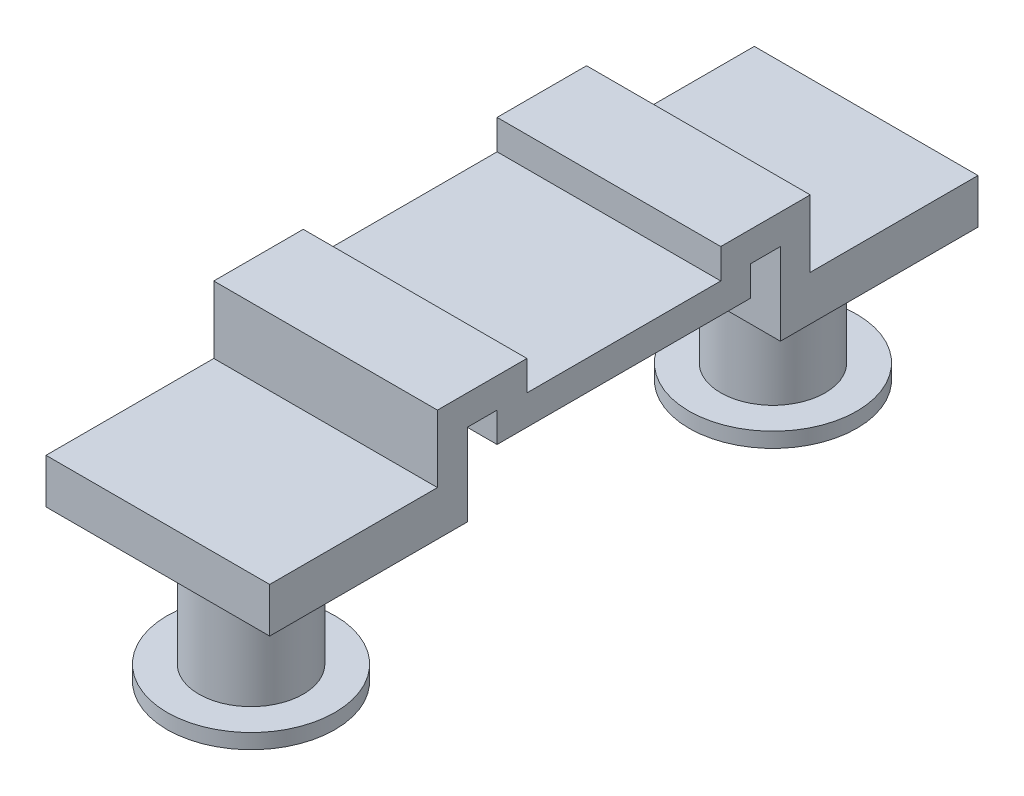
from build123d import *

# Parameters (mm, degrees)
BOSS_EXTRUDE4_DEPTH = 3
SKETCH5_R           = 1.4
BOSS_EXTRUDE5_DEPTH = 4.6
SKETCH6_R           = 2.25
BOSS_EXTRUDE6_DEPTH = 0.4


with BuildPart() as part:
    # Sketch4 → Boss-Extrude4 (new body, symmetric)
    with BuildSketch(Plane(origin=(0, 0, 0), x_dir=(0, 0, -1), z_dir=(1, 0, 0))):
        Polygon((-5, -1), (-5, 0.8), (-2.6, 0.8), (-2.6, 0), (2.6, 0), (2.6, 0.8), (5, 0.8), (5, -1), (9.5, -1), (9.5, -2.2), (4.2, -2.2), (4.2, 0), (3.4, 0), (3.4, -0.8), (-3.4, -0.8), (-3.4, 0), (-4.2, 0), (-4.2, -2.2), (-9.5, -2.2), (-9.5, -1), align=None)
    extrude(amount=BOSS_EXTRUDE4_DEPTH, both=True)

    # Sketch5 → Boss-Extrude5 (add)
    with BuildSketch(Plane(origin=(0, -1, 0), x_dir=(1, 0, 0), z_dir=(0, 1, 0))):
        with Locations((0, -7)):
            Circle(SKETCH5_R)
        with Locations((0, 7)):
            Circle(SKETCH5_R)
    extrude(amount=-BOSS_EXTRUDE5_DEPTH)

    # Sketch6 → Boss-Extrude6 (add)
    with BuildSketch(Plane.XZ.offset(5.6)):
        with Locations((0, -7)):
            Circle(SKETCH6_R)
        with Locations((0, 7)):
            Circle(SKETCH6_R)
    extrude(amount=BOSS_EXTRUDE6_DEPTH)


solid = part.part
